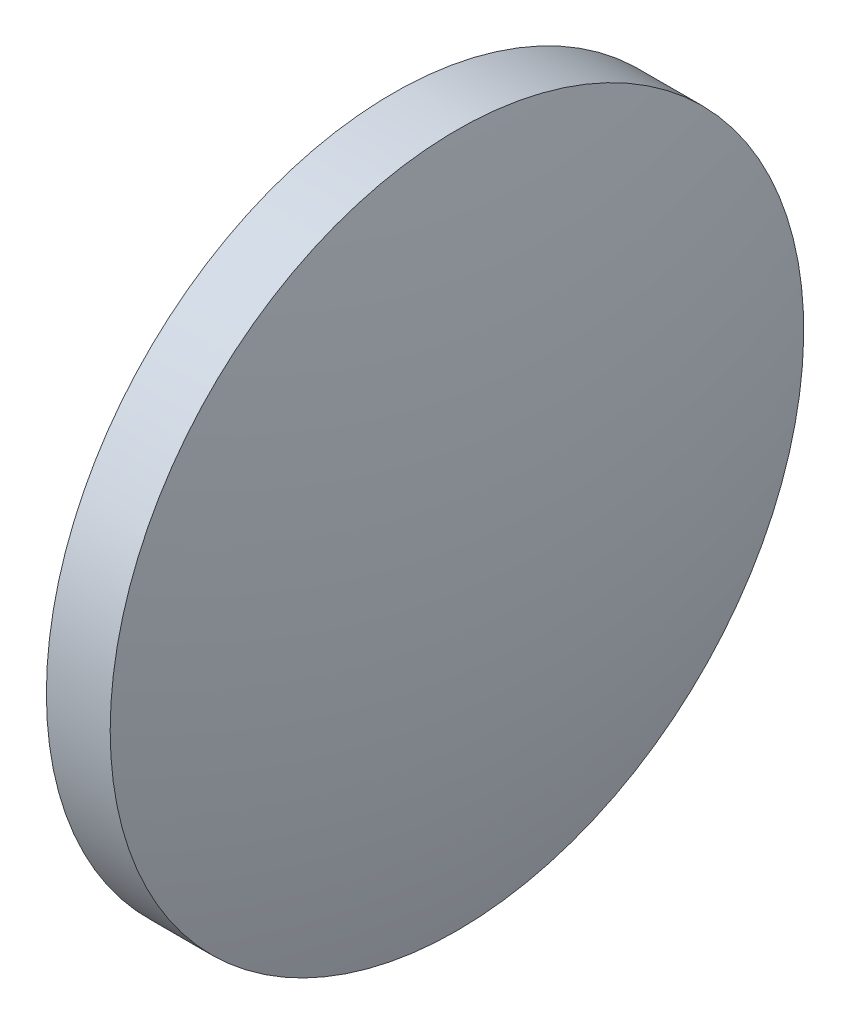
from build123d import *


with BuildPart() as part:
    # 草图1 → 旋转1 (revolve)
    with BuildSketch(Plane.XY, mode=Mode.PRIVATE) as revolve_1_sk:
        with BuildLine():
            Line((578.9881568, 147.276559922), (578.9881568, 154.776559922))
            Line((578.9881568, 154.776559922), (580.3681568, 154.776559922))
            ThreePointArc((580.3681568, 154.776559922), (581.057298039, 151.054667914), (581.2881568, 147.276559922))
            Line((581.2881568, 147.276559922), (578.9881568, 147.276559922))
        make_face()
    revolve(revolve_1_sk.sketch.rotate(Axis((576.661469742, 147.276559922, 0), (1, 0, 0)), 180), axis=Axis((576.661469742, 147.276559922, 0), (1, 0, 0)))  # turned: the seam where the file's is


solid = part.part
